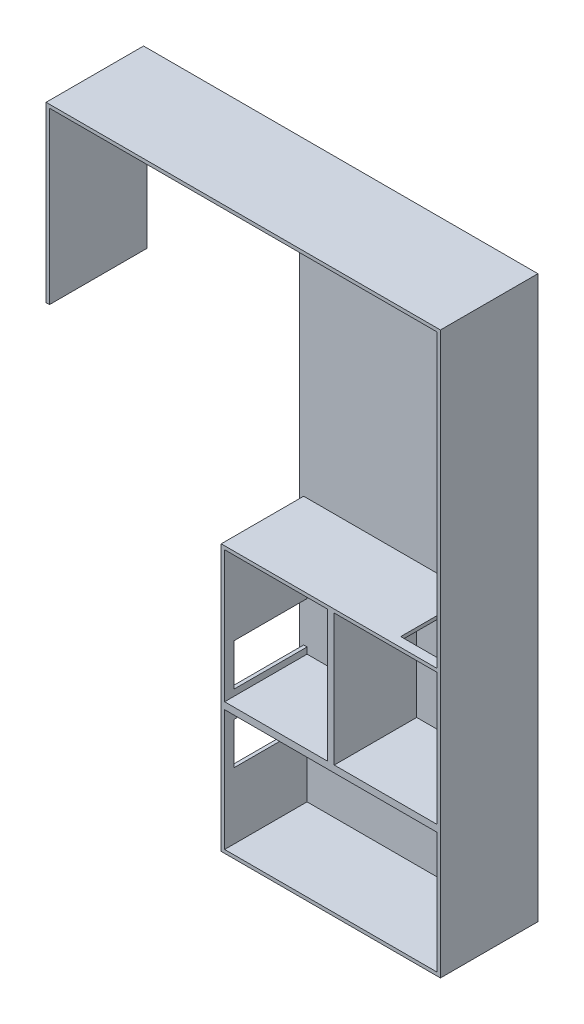
from build123d import *

# Parameters (mm, degrees)
SKETCH1_W           = 6525
SKETCH1_H           = 16410
BOSS_EXTRUDE1_DEPTH = 440
SKETCH2_W           = 3205
SKETCH2_H           = 4050
SKETCH2_W_2         = 3005
SKETCH2_H_2         = 3850
SKETCH2_W_3         = 6410
SKETCH2_H_3         = 3740
SKETCH2_W_4         = 6210
SKETCH2_H_4         = 3540
BOSS_EXTRUDE2_DEPTH = 2850
SKETCH6_W           = 2135
SKETCH6_H           = 1224
CUT_EXTRUDE2_DEPTH  = 1036
SKETCH7_W           = 1225
SKETCH7_H           = 2135
CUT_EXTRUDE3_DEPTH  = 1036


with BuildPart() as part:
    # Sketch1 → Boss-Extrude1 (new body)
    with BuildSketch(Plane(origin=(0, 0, 38431.700196057), x_dir=(-1, 0, 0), z_dir=(0, 0, -1))):
        with Locations((11259.117683291, 11712.481366586)):
            Rectangle(SKETCH1_W, SKETCH1_H)
    extrude(amount=-BOSS_EXTRUDE1_DEPTH)

    # Sketch2 → Boss-Extrude2 (add)
    with BuildSketch(Plane(origin=(0, 0, 38431.700196057), x_dir=(-1, 0, 0), z_dir=(0, 0, -1))):
        with Locations((12804.117683291, 9272.481366586)):
            Rectangle(SKETCH2_W, SKETCH2_H)
        with Locations((12804.117683291, 9272.481366586)):
            Rectangle(SKETCH2_W_2, SKETCH2_H_2, mode=Mode.SUBTRACT)
        with Locations((11201.617683291, 5377.481366586)):
            Rectangle(SKETCH2_W_3, SKETCH2_H_3)
        with Locations((11201.617683291, 5377.481366586)):
            Rectangle(SKETCH2_W_4, SKETCH2_H_4, mode=Mode.SUBTRACT)
        Polygon((7996.617683291, 11297.481366586), (7996.617683291, 7247.481366586), (11201.617683291, 7247.481366586), (11201.617683291, 11297.481366586), (8096.617683291, 11297.481366586), align=None)
        with Locations((9599.117683291, 9272.481366586)):
            Rectangle(SKETCH2_W_2, SKETCH2_H_2, mode=Mode.SUBTRACT)
        Polygon((7996.617683291, 11297.481366586), (7996.617683291, 19917.481366586), (19527.290870624, 19917.481366586), (19527.290870624, 14843.336774649), (19427.290870624, 14843.336774649), (19427.290870624, 19817.481366586), (8096.617683291, 19817.481366586), (8096.617683291, 11297.481366586), align=None)
    extrude(amount=-BOSS_EXTRUDE2_DEPTH)

    # Sketch6 → Cut-Extrude2 (cut)
    with BuildSketch(Plane.ZY.offset(14406.617683291)):
        with Locations((39939.200196057, 8143.108207073)):
            Rectangle(SKETCH6_W, SKETCH6_H)
        with Locations((39939.200196057, 6151.854526099)):
            Rectangle(SKETCH6_W, SKETCH6_H)
    extrude(amount=-CUT_EXTRUDE2_DEPTH, mode=Mode.SUBTRACT)

    # Sketch7 → Cut-Extrude3 (cut)
    with BuildSketch(Plane(origin=(0, 11297.481366586, 0), x_dir=(1, 0, 0), z_dir=(0, 1, 0))):
        with Locations((-8820.615695145, -39939.200196057)):
            Rectangle(SKETCH7_W, SKETCH7_H)
    extrude(amount=-CUT_EXTRUDE3_DEPTH, mode=Mode.SUBTRACT)


solid = part.part
